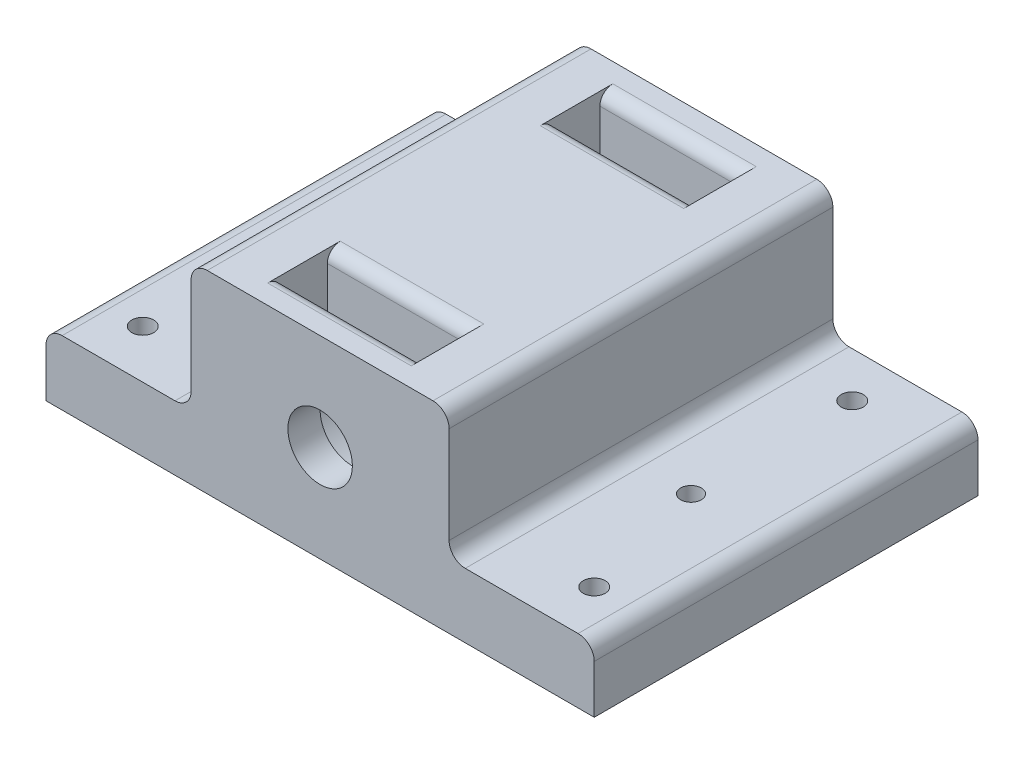
from build123d import *

# Parameters (mm, degrees)
SKETCH2_R                = 5
BOSS_EXTRUDE1_DEPTH      = 15
BOSS_EXTRUDE1_DEPTH_BACK = 44.5
SKETCH3_R                = 1.6
SKETCH3_R_2              = 1.7
CUT_EXTRUDE1_DEPTH       = 31
CUT_EXTRUDE1_DEPTH_BACK  = 1
FILLET1_R                = 2.5
CUT_EXTRUDE5_START       = 10
CUT_EXTRUDE5_DEPTH       = 7.25
CUT_EXTRUDE6_START       = -39.5
CUT_EXTRUDE6_DEPTH       = 7.25
FILLET2_R                = 2


with BuildPart() as part:
    # Sketch2 → Boss-Extrude1 (new body, two sides)
    with BuildSketch(Plane.XY) as boss_extrude1_sk:
        Polygon((0, 10), (0, 0), (85, 0), (85, 10), (62.5, 10), (62.5, 30), (22.5, 30), (22.5, 10), align=None)
        with Locations((42.5, 15)):
            Circle(SKETCH2_R, mode=Mode.SUBTRACT)
    extrude(amount=BOSS_EXTRUDE1_DEPTH)
    extrude(boss_extrude1_sk.sketch, amount=-BOSS_EXTRUDE1_DEPTH_BACK)

    # Sketch3 → Cut-Extrude1 (cut, two sides)
    with BuildSketch(Plane(origin=(0, 0, 0), x_dir=(1, 0, 0), z_dir=(0, 1, 0))) as cut_extrude1_sk:
        with Locations((72.5, 12.5)):
            Circle(SKETCH3_R)
        with Locations((12.5, 12.5)):
            Circle(SKETCH3_R)
        with Locations((7.5, -7.5)):
            Circle(SKETCH3_R_2)
        with Locations((77.5, -7.5)):
            Circle(SKETCH3_R_2)
        with Locations((12.5, 37.5)):
            Circle(SKETCH3_R_2)
        with Locations((72.5, 37.5)):
            Circle(SKETCH3_R_2)
    extrude(amount=CUT_EXTRUDE1_DEPTH, mode=Mode.SUBTRACT)
    extrude(cut_extrude1_sk.sketch, amount=-CUT_EXTRUDE1_DEPTH_BACK, mode=Mode.SUBTRACT)

    # Fillet1
    fillet1_edges = [part.edges().sort_by_distance(p)[0] for p in [
        (62.5, 30, -14.75),
        (62.5, 10, -14.75),
        (85, 10, -14.75),
        (0, 10, -14.75),
        (22.5, 10, -14.75),
        (22.5, 30, -14.75),
    ]]
    fillet(fillet1_edges, radius=FILLET1_R)

    # Sketch5 → Cut-Extrude5 (cut)
    with BuildSketch(Plane.XY.offset(CUT_EXTRUDE5_START)):
        with BuildLine():
            Line((31.375, 30), (31.375, 15))
            ThreePointArc((31.375, 15), (42.5, 3.875), (53.625, 15))
            Line((53.625, 15), (53.625, 30))
            Line((53.625, 30), (31.375, 30))
        make_face()
    extrude(amount=-CUT_EXTRUDE5_DEPTH, mode=Mode.SUBTRACT)

    # Sketch5_2 → Cut-Extrude6 (cut)
    with BuildSketch(Plane.XY.offset(CUT_EXTRUDE6_START)):
        with BuildLine():
            Line((31.375, 30), (31.375, 15))
            ThreePointArc((31.375, 15), (42.5, 3.875), (53.625, 15))
            Line((53.625, 15), (53.625, 30))
            Line((53.625, 30), (31.375, 30))
        make_face()
    extrude(amount=CUT_EXTRUDE6_DEPTH, mode=Mode.SUBTRACT)

    # Fillet2
    fillet2_edges = [part.edges().sort_by_distance(p)[0] for p in [
        (42.5, 30, 2.75),
        (42.5, 30, 10),
        (42.5, 30, -39.5),
        (42.5, 30, -32.25),
    ]]
    fillet(fillet2_edges, radius=FILLET2_R)


solid = part.part
